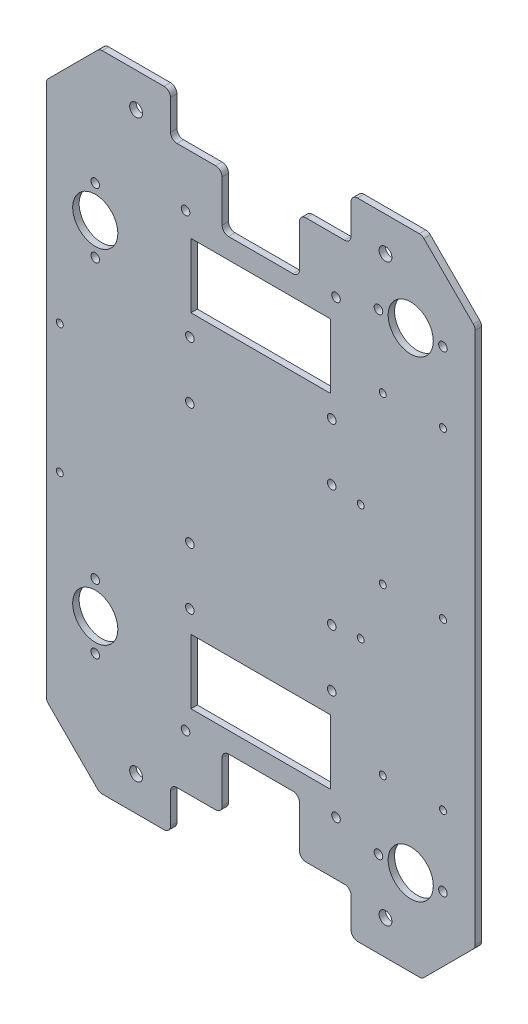
from build123d import *

# Parameters (mm, degrees)
BASE_DEPTH                = 3
ESQUISSE3_R               = 2
ESQUISSE3_W               = 65
ESQUISSE3_H               = 30
ENL_V_MAT_EXTRU_1_DEPTH   = 4
CONG_1_R                  = 3
ESQUISSE6_R               = 2
ESQUISSE6_R_2             = 10.5
PER_AGE_POUR_BILLES_DEPTH = 3
PER_AGE_POUR_PROFIL_REACH = 5
ESQUISSE8_R               = 3
ESQUISSE10_R              = 2
ENL_V_MAT_EXTRU_3_DEPTH   = 4
ESQUISSE12_R              = 1.625
ENL_V_MAT_EXTRU_4_DEPTH   = 4
ESQUISSE13_R              = 1.625
ENL_V_MAT_EXTRU_5_DEPTH   = 4


with BuildPart() as part:
    # Esquisse1 → Base (new body)
    with BuildSketch(Plane.XY):
        Polygon((0, 0), (-150, 0), (-174.748737342, 24.748737342), (-174.748737342, 274.748737342), (-150, 299.497474683), (0, 299.497474683), (24.748737342, 274.748737342), (24.748737342, 24.748737342), align=None)
    extrude(amount=BASE_DEPTH)

    # Esquisse3 → Enlèv. mat.-Extru.1 (cut, through all)
    with BuildSketch(Plane(origin=(0, 0, 0), x_dir=(-1, 0, 0), z_dir=(0, 0, -1))):
        with Locations((40, 45)):
            Circle(ESQUISSE3_R)
        with Locations((110, 45)):
            Circle(ESQUISSE3_R)
        with Locations((110, 254.497474683)):
            Circle(ESQUISSE3_R)
        with Locations((40, 254.497474683)):
            Circle(ESQUISSE3_R)
        Polygon((117, 0), (117, 20), (93, 20), (93, 45.5), (57, 45.5), (57, 20), (33, 20), (33, 0), align=None)
        Polygon((33, 299.497474683), (117, 299.497474683), (117, 279.497474683), (93, 279.497474683), (93, 253.997474683), (57, 253.997474683), (57, 279.497474683), (33, 279.497474683), align=None)
        with Locations((75, 229.497474683)):
            Rectangle(ESQUISSE3_W, ESQUISSE3_H)
        with Locations((75, 70)):
            Rectangle(ESQUISSE3_W, ESQUISSE3_H)
    extrude(amount=-ENL_V_MAT_EXTRU_1_DEPTH, mode=Mode.SUBTRACT)

    # Congé1
    cong_1_edges = [part.edges().sort_by_distance(p)[0] for p in [
        (0, 0, 1.5),
        (-150, 0, 1.5),
        (-174.748737342, 24.748737342, 1.5),
        (-174.748737342, 274.748737342, 1.5),
        (-150, 299.497474683, 1.5),
        (0, 299.497474683, 1.5),
        (24.748737342, 274.748737342, 1.5),
        (24.748737342, 24.748737342, 1.5),
        (-33, 279.497474683, 1.5),
        (-33, 299.497474683, 1.5),
        (-117, 299.497474683, 1.5),
        (-117, 279.497474683, 1.5),
        (-93, 279.497474683, 1.5),
        (-93, 253.997474683, 1.5),
        (-57, 253.997474683, 1.5),
        (-57, 279.497474683, 1.5),
        (-117, 0, 1.5),
        (-33, 0, 1.5),
        (-33, 20, 1.5),
        (-57, 20, 1.5),
        (-57, 45.5, 1.5),
        (-93, 45.5, 1.5),
        (-93, 20, 1.5),
        (-117, 20, 1.5),
    ]]
    fillet(cong_1_edges, radius=CONG_1_R)

    # Esquisse6 → Perçage pour billes (cut)
    with BuildSketch(Plane.XY.offset(3)):
        with Locations((-152, 55)):
            Circle(ESQUISSE6_R)
        with Locations((-152, 85)):
            Circle(ESQUISSE6_R)
        with Locations((-152, 70)):
            Circle(ESQUISSE6_R_2)
        with Locations((-5.251262658, 40)):
            Circle(ESQUISSE6_R_2)
        with Locations((-20.251262658, 40)):
            Circle(ESQUISSE6_R)
        with Locations((9.748737342, 40)):
            Circle(ESQUISSE6_R)
    per_age_pour_billes = extrude(amount=-PER_AGE_POUR_BILLES_DEPTH, mode=Mode.SUBTRACT)

    # Esquisse8 → Perçage pour profilé (cut, up to next)
    with BuildSketch(Plane.XY.offset(3), mode=Mode.PRIVATE) as per_age_pour_profil_sk1:
        with Locations((-133, 16)):
            Circle(ESQUISSE8_R)
    per_age_pour_profil_tool1 = extrude(per_age_pour_profil_sk1.sketch, amount=-PER_AGE_POUR_PROFIL_REACH, mode=Mode.PRIVATE) & part.part
    add(per_age_pour_profil_tool1.solids().sort_by_distance((-133, 16, 3))[0], mode=Mode.SUBTRACT)
    # Esquisse8 → Perçage pour profilé (cut, up to next)
    with BuildSketch(Plane.XY.offset(3), mode=Mode.PRIVATE) as per_age_pour_profil_sk2:
        with Locations((-133, 283.497474683)):
            Circle(ESQUISSE8_R)
    per_age_pour_profil_tool2 = extrude(per_age_pour_profil_sk2.sketch, amount=-PER_AGE_POUR_PROFIL_REACH, mode=Mode.PRIVATE) & part.part
    add(per_age_pour_profil_tool2.solids().sort_by_distance((-133, 283.497475, 3))[0], mode=Mode.SUBTRACT)
    # Esquisse8 → Perçage pour profilé (cut, up to next)
    with BuildSketch(Plane.XY.offset(3), mode=Mode.PRIVATE) as per_age_pour_profil_sk3:
        with Locations((-17, 283.497474683)):
            Circle(ESQUISSE8_R)
    per_age_pour_profil_tool3 = extrude(per_age_pour_profil_sk3.sketch, amount=-PER_AGE_POUR_PROFIL_REACH, mode=Mode.PRIVATE) & part.part
    add(per_age_pour_profil_tool3.solids().sort_by_distance((-17, 283.497475, 3))[0], mode=Mode.SUBTRACT)
    # Esquisse8 → Perçage pour profilé (cut, up to next)
    with BuildSketch(Plane.XY.offset(3), mode=Mode.PRIVATE) as per_age_pour_profil_sk4:
        with Locations((-17, 16)):
            Circle(ESQUISSE8_R)
    per_age_pour_profil_tool4 = extrude(per_age_pour_profil_sk4.sketch, amount=-PER_AGE_POUR_PROFIL_REACH, mode=Mode.PRIVATE) & part.part
    add(per_age_pour_profil_tool4.solids().sort_by_distance((-17, 16, 3))[0], mode=Mode.SUBTRACT)

    # Esquisse10 → Enlèv. mat.-Extru.3 (cut, through all)
    with BuildSketch(Plane.XY.offset(3)):
        with Locations((-108, 204.497474683)):
            Circle(ESQUISSE10_R)
        with Locations((-108, 177.997474683)):
            Circle(ESQUISSE10_R)
        with Locations((-42, 177.997474683)):
            Circle(ESQUISSE10_R)
        with Locations((-42, 204.497474683)):
            Circle(ESQUISSE10_R)
        with Locations((-42, 121.5)):
            Circle(ESQUISSE10_R)
        with Locations((-42, 95)):
            Circle(ESQUISSE10_R)
        with Locations((-108, 121.5)):
            Circle(ESQUISSE10_R)
        with Locations((-108, 95)):
            Circle(ESQUISSE10_R)
    extrude(amount=-ENL_V_MAT_EXTRU_3_DEPTH, mode=Mode.SUBTRACT)

    # Symétrie2: Perçage pour billes across plane
    add(per_age_pour_billes.mirror(Plane.ZX.offset(149.748737342)), mode=Mode.SUBTRACT)

    # Esquisse12 → Enlèv. mat.-Extru.4 (cut, through all)
    with BuildSketch(Plane(origin=(0, 0, 0), x_dir=(-1, 0, 0), z_dir=(0, 0, -1))):
        with Locations((-9.748737342, 72.748737342)):
            Circle(ESQUISSE12_R)
        with Locations((-9.748737342, 149.748737342)):
            Circle(ESQUISSE12_R)
        with Locations((-9.748737342, 226.748737342)):
            Circle(ESQUISSE12_R)
        with Locations((18.251262658, 226.748737342)):
            Circle(ESQUISSE12_R)
        with Locations((18.251262658, 149.748737342)):
            Circle(ESQUISSE12_R)
        with Locations((18.251262658, 72.748737342)):
            Circle(ESQUISSE12_R)
    extrude(amount=-ENL_V_MAT_EXTRU_4_DEPTH, mode=Mode.SUBTRACT)

    # Esquisse13 → Enlèv. mat.-Extru.5 (cut, through all)
    with BuildSketch(Plane(origin=(0, 0, 0), x_dir=(-1, 0, 0), z_dir=(0, 0, -1))):
        with Locations((28.501262658, 122.748737342)):
            Circle(ESQUISSE13_R)
        with Locations((28.501262658, 176.748737342)):
            Circle(ESQUISSE13_R)
        with Locations((168.498737342, 119.748737342)):
            Circle(ESQUISSE13_R)
        with Locations((168.498737342, 179.748737342)):
            Circle(ESQUISSE13_R)
    extrude(amount=-ENL_V_MAT_EXTRU_5_DEPTH, mode=Mode.SUBTRACT)


solid = part.part
